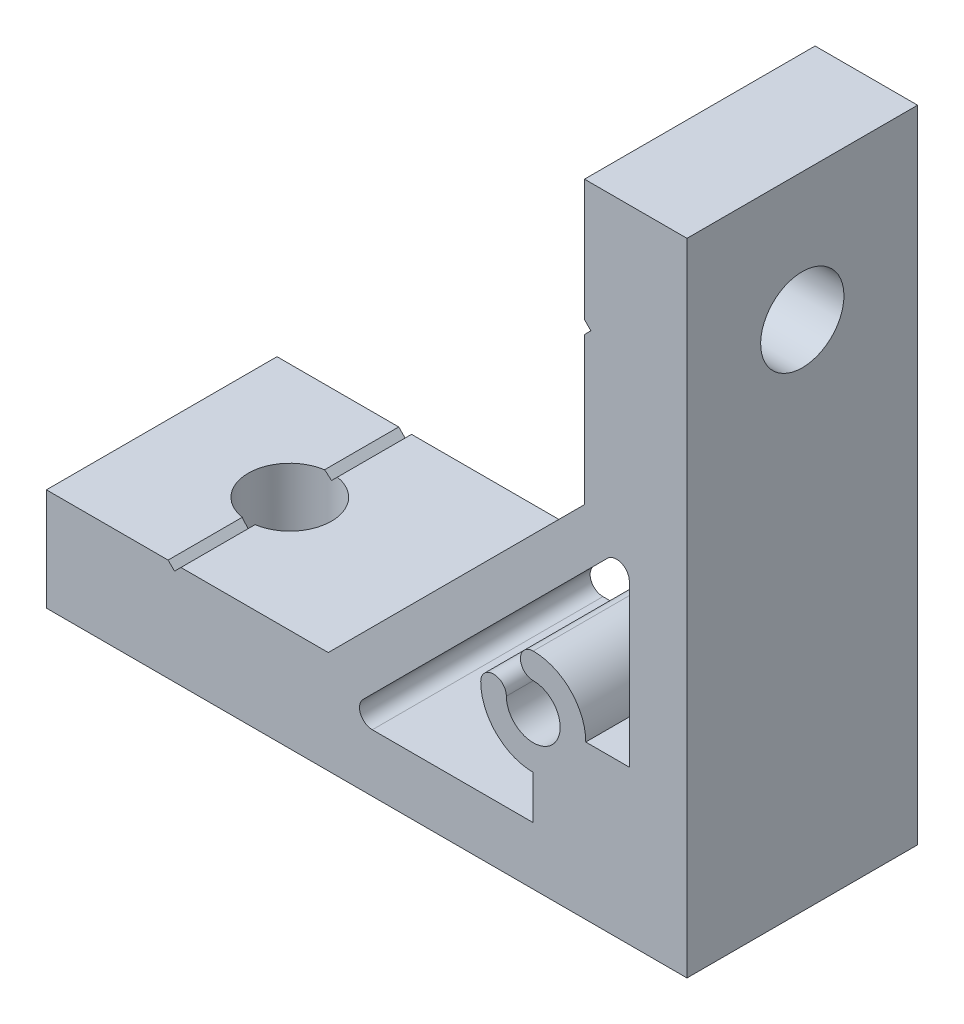
from build123d import *

# Parameters (mm, degrees)
EXTRUDE_1_DEPTH     = 9
SKETCH_2_R          = 3.25
CUT_EXTRUDE_1_DEPTH = 9
SKETCH_3_R          = 3.25
CUT_EXTRUDE_2_DEPTH = 9


with BuildPart() as part:
    # Эскиз1 → Бобышка-Вытянуть1 (new body, symmetric)
    with BuildSketch(Plane.XY):
        Polygon((-50, 0), (0, 0), (0, 50), (-8, 50), (-8, 40.5), (-7.5, 40), (-8, 39.5), (-8, 28), (-28, 8), (-39.5, 8), (-40, 7.5), (-40.5, 8), (-50, 8), align=None)
        with BuildLine():
            Line((-4.5, 12), (-4.5, 24.560303038))
            ThreePointArc((-4.5, 24.560303038), (-5.117316568, 25.484182571), (-6.207106781, 25.267409819))
            Line((-6.207106781, 25.267409819), (-25.267409819, 6.207106781))
            ThreePointArc((-25.267409819, 6.207106781), (-25.484182571, 5.117316568), (-24.560303038, 4.5))
            Line((-24.560303038, 4.5), (-12, 4.5))
            Line((-12, 4.5), (-12, 7.9))
            ThreePointArc((-12, 7.9), (-14.899137803, 9.100862197), (-16.1, 12))
            ThreePointArc((-16.1, 12), (-15.1, 13), (-14.1, 12))
            ThreePointArc((-14.1, 12), (-10.51507576, 10.51507576), (-12, 14.1))
            ThreePointArc((-12, 14.1), (-13, 15.1), (-12, 16.1))
            ThreePointArc((-12, 16.1), (-9.100862197, 14.899137803), (-7.9, 12))
            Line((-7.9, 12), (-4.5, 12))
        make_face(mode=Mode.SUBTRACT)
    extrude(amount=EXTRUDE_1_DEPTH, both=True)

    # Эскиз2 → Вырез-Вытянуть1 (cut, through all)
    with BuildSketch(Plane.ZY.offset(8)):
        with Locations(Location((0, 40, 0), (0, 0, 270))):  # turned: the seam where the file's is
            Circle(SKETCH_2_R)
    extrude(amount=-CUT_EXTRUDE_1_DEPTH, mode=Mode.SUBTRACT)

    # Эскиз3 → Вырез-Вытянуть2 (cut, through all)
    with BuildSketch(Plane(origin=(0, 8, 0), x_dir=(1, 0, 0), z_dir=(0, 1, 0))):
        with Locations(Location((-40, 0, 0), (0, 0, 180))):  # turned: the seam where the file's is
            Circle(SKETCH_3_R)
    extrude(amount=-CUT_EXTRUDE_2_DEPTH, mode=Mode.SUBTRACT)


solid = part.part
